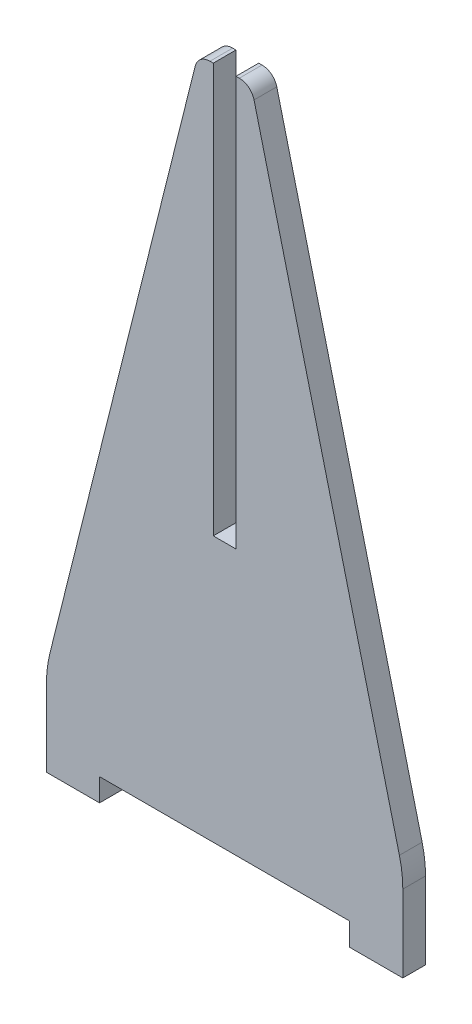
from build123d import *

# Parameters (mm, degrees)
RESSALTO_EXTRUS_O1_DEPTH = 3
FILETE1_R                = 15
FILETE2_R                = 2


with BuildPart() as part:
    # Esboço1 → Ressalto-extrusão1 (new body)
    with BuildSketch(Plane.XY):
        Polygon((-23.5, 0), (-16.5, 0), (-16.5, 3), (16.5, 3), (16.5, 0), (23.5, 0), (23.5, 12), (3.5, 92), (1.5, 92), (1.5, 38), (-1.5, 38), (-1.5, 92), (-3.5, 92), (-23.5, 12), align=None)
    extrude(amount=RESSALTO_EXTRUS_O1_DEPTH)

    # Filete1
    filete1_edges = [part.edges().sort_by_distance(p)[0] for p in [
        (-23.5, 12, 1.5),
        (23.5, 12, 1.5),
    ]]
    fillet(filete1_edges, radius=FILETE1_R)

    # Filete2
    filete2_edges = [part.edges().sort_by_distance(p)[0] for p in [
        (-3.5, 92, 1.5),
        (3.5, 92, 1.5),
    ]]
    fillet(filete2_edges, radius=FILETE2_R)


solid = part.part
